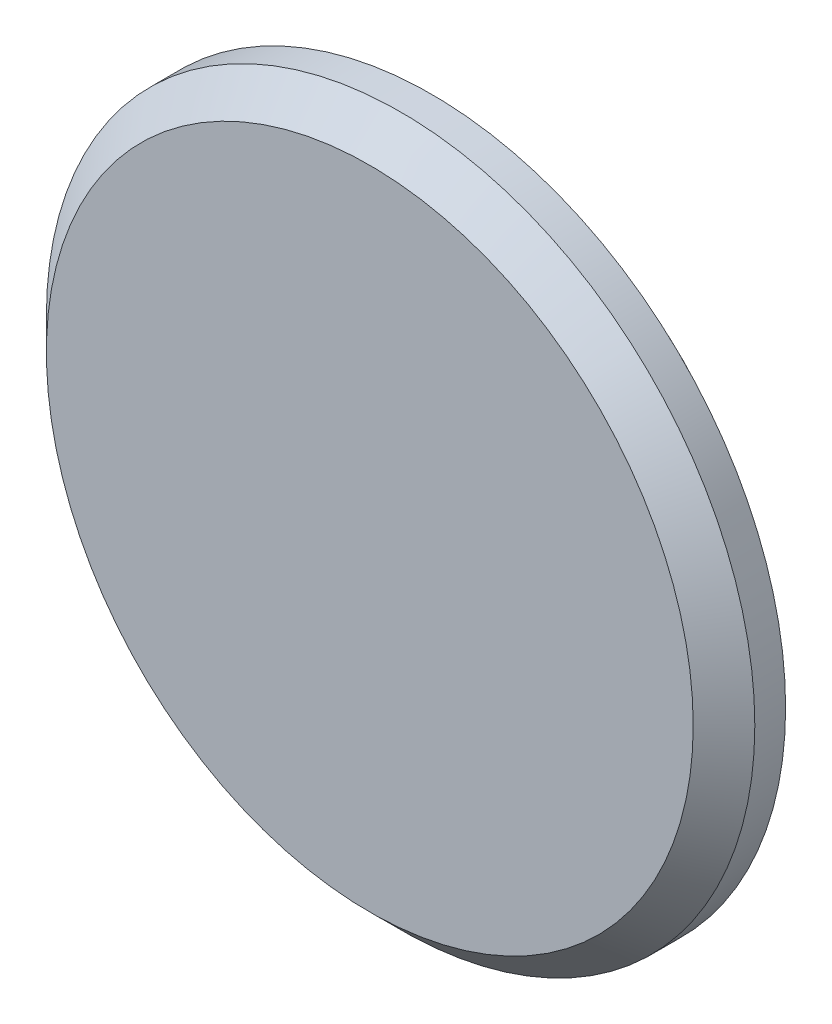
from build123d import *

# Parameters (mm, degrees)
SKETCH1_R           = 30.0863
BOSS_EXTRUDE1_DEPTH = 6.35
SKETCH2_R           = 36.5125
BOSS_EXTRUDE2_DEPTH = 6.35
CHAMFER1_SIZE       = 3.175
CHAMFER2_SIZE       = 2.54


with BuildPart() as part:
    # Sketch1 → Boss-Extrude1 (new body)
    with BuildSketch(Plane.XY):
        Circle(SKETCH1_R)
    extrude(amount=-BOSS_EXTRUDE1_DEPTH)

    # Sketch2 → Boss-Extrude2 (add)
    with BuildSketch(Plane.XY):
        Circle(SKETCH2_R)
    extrude(amount=BOSS_EXTRUDE2_DEPTH)

    # Chamfer1
    chamfer1_edges = [part.edges().sort_by_distance(p)[0] for p in [
        (-36.5125, 0, 6.35),
    ]]
    chamfer(chamfer1_edges, length=CHAMFER1_SIZE)

    # Chamfer2
    chamfer2_edges = [part.edges().sort_by_distance(p)[0] for p in [
        (-30.0863, 0, -6.35),
    ]]
    chamfer(chamfer2_edges, length=CHAMFER2_SIZE)


solid = part.part
